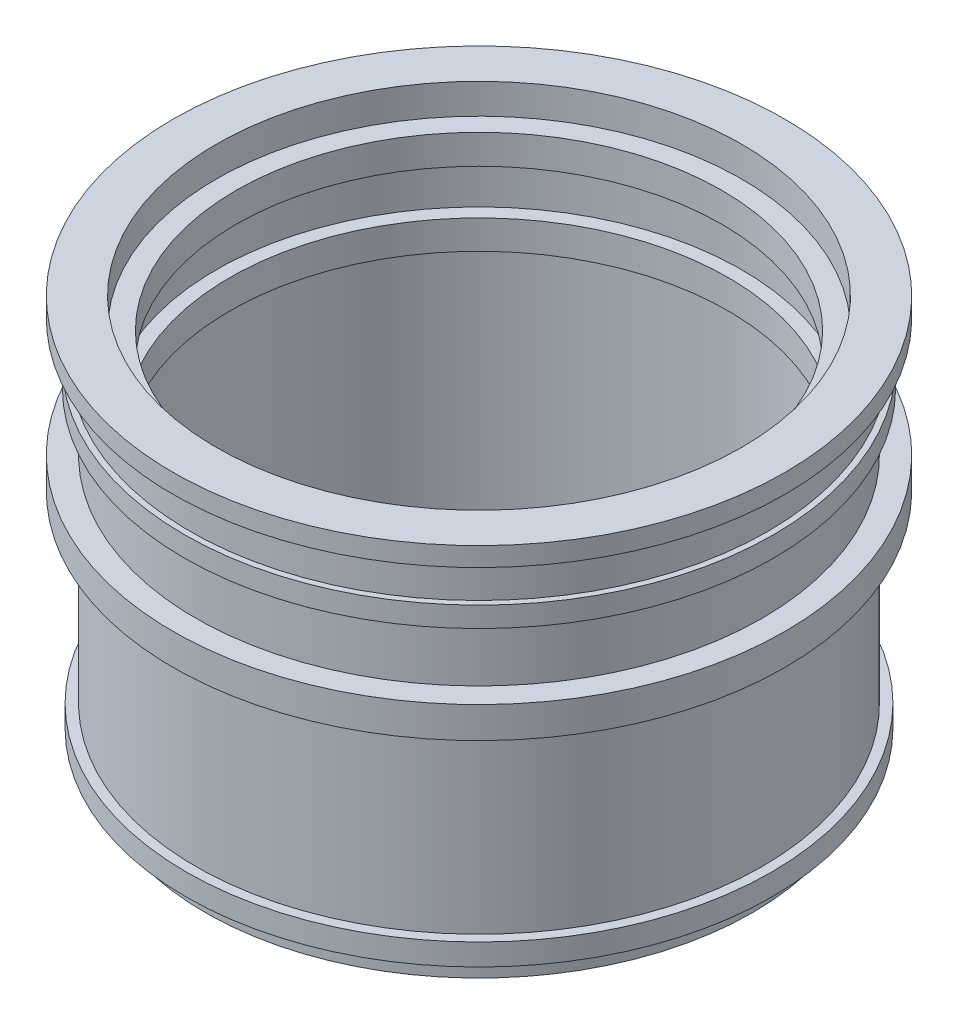
from build123d import *


with BuildPart() as part:
    # Sketch1 → Revolve1 (revolve)
    with BuildSketch(Plane.XY):
        Polygon((-75.784806401, 0), (-75.784806401, 6.356320182), (-81.037271199, 6.356320182), (-81.037271199, 12.359137093), (-78.4110388, 12.359137093), (-78.4110388, 63.243015116), (-84.710995149, 63.243015116), (-84.710995149, 71.887071469), (-78.4110388, 71.887071469), (-78.4110388, 87.878575722), (-81.561016974, 87.878575722), (-81.561016974, 93.497212352), (-79.986027887, 93.497212352), (-79.986027887, 104.734485611), (-84.710995149, 104.734485611), (-84.710995149, 110), (-72.728358467, 110), (-72.728358467, 101.639947534), (-67.271641533, 101.639947534), (-67.271641533, 93.497212352), (-72.728358467, 93.497212352), (-72.728358467, 79.882823596), (-69, 79.882823596), (-69, 71.887071469), (-70, 71.887071469), (-70, 0), align=None)
    revolve(axis=Axis((0, -0.310935058, 0), (0, 1, 0)))


solid = part.part
